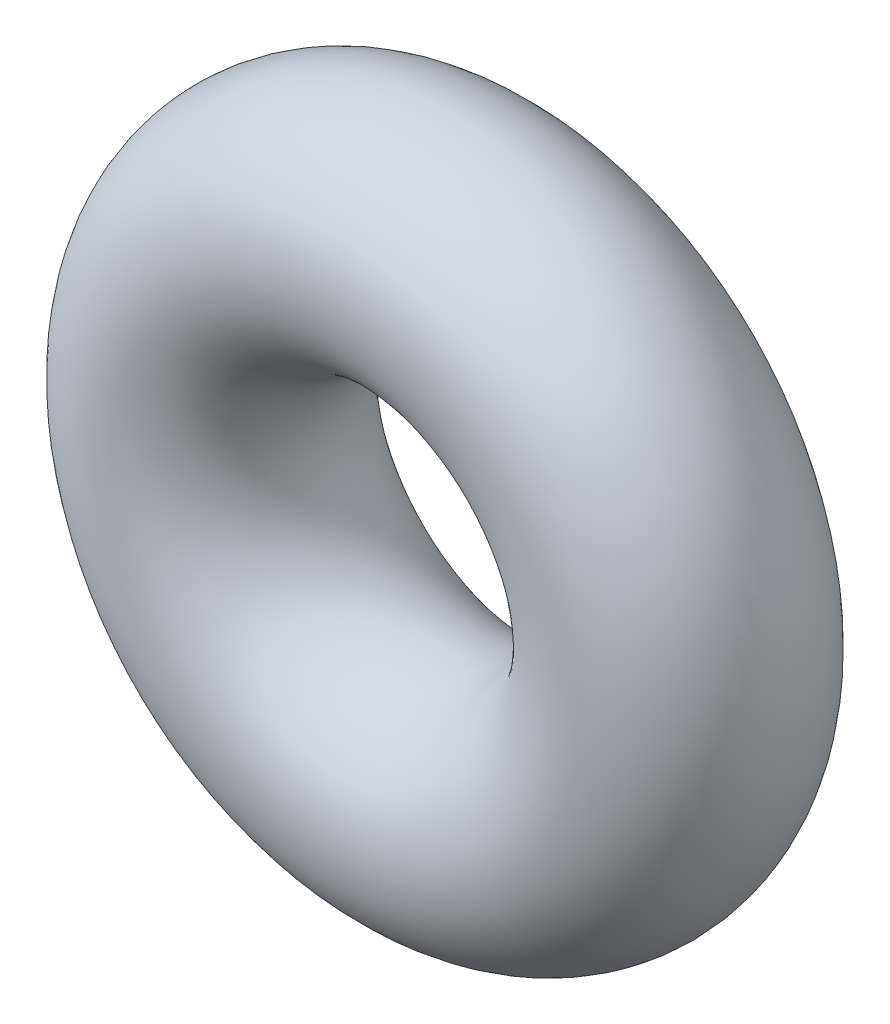
from build123d import *

# Parameters (mm, degrees)
SKETCH1_R = 0.889


with BuildPart() as part:
    # Sketch1 → Revolve1 (revolve)
    with BuildSketch(Plane(origin=(0, 0, 0), x_dir=(0, -1, 0), z_dir=(1, 0, 0))):
        with Locations((1.778, 0)):
            Circle(SKETCH1_R)
    revolve(axis=Axis((0, 0, 0.889), (0, 0, -1)))


solid = part.part
